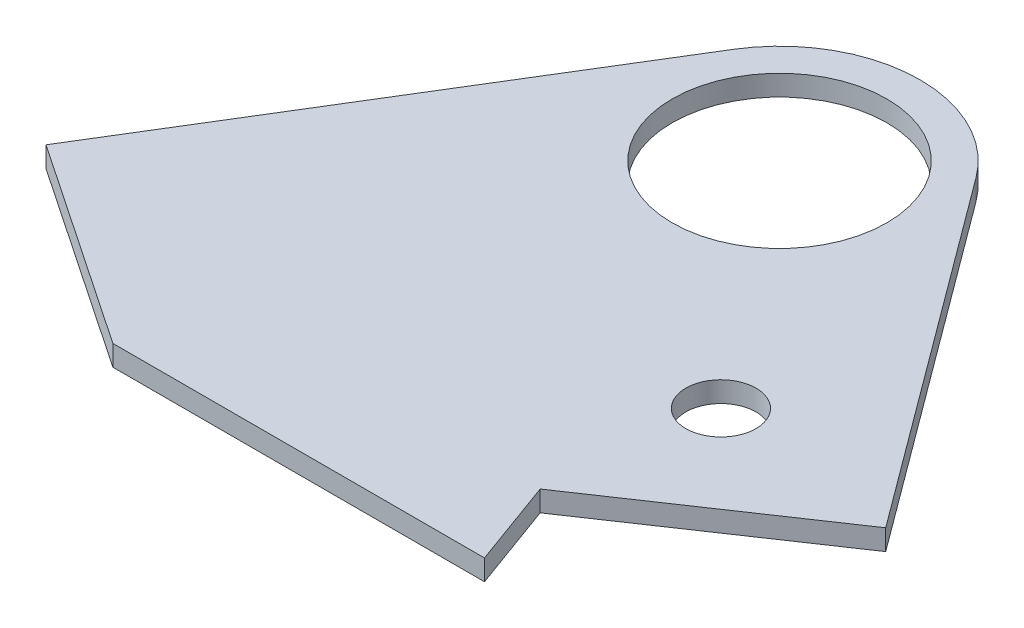
from build123d import *

# Parameters (mm, degrees)
SKETCH1_R           = 13
SKETCH1_R_2         = 4.25
BOSS_EXTRUDE1_DEPTH = 1.25


with BuildPart() as part:
    # Sketch1 → Boss-Extrude1 (new body, symmetric)
    with BuildSketch(Plane(origin=(0, 0, 0), x_dir=(1, 0, 0), z_dir=(0, 1, 0))):
        with BuildLine():
            Line((-21.223783798, -59.5), (23.776216202, -59.5))
            Line((23.776216202, -59.5), (19.918131719, -48.9))
            Line((19.918131719, -48.9), (44.905089026, -32.046084487))
            Line((44.905089026, -32.046084487), (13.660617354, 10.13521746))
            ThreePointArc((13.660617354, 10.13521746), (-0.749839352, 17), (-14.499227131, 8.891927633))
            Line((-14.499227131, 8.891927633), (-46.094910974, -42.724212896))
            Line((-46.094910974, -42.724212896), (-21.223783798, -59.5))
        make_face()
        Circle(SKETCH1_R, mode=Mode.SUBTRACT)
        with Locations((22.405089026, -29.5)):
            Circle(SKETCH1_R_2, mode=Mode.SUBTRACT)
    extrude(amount=BOSS_EXTRUDE1_DEPTH, both=True)


solid = part.part
